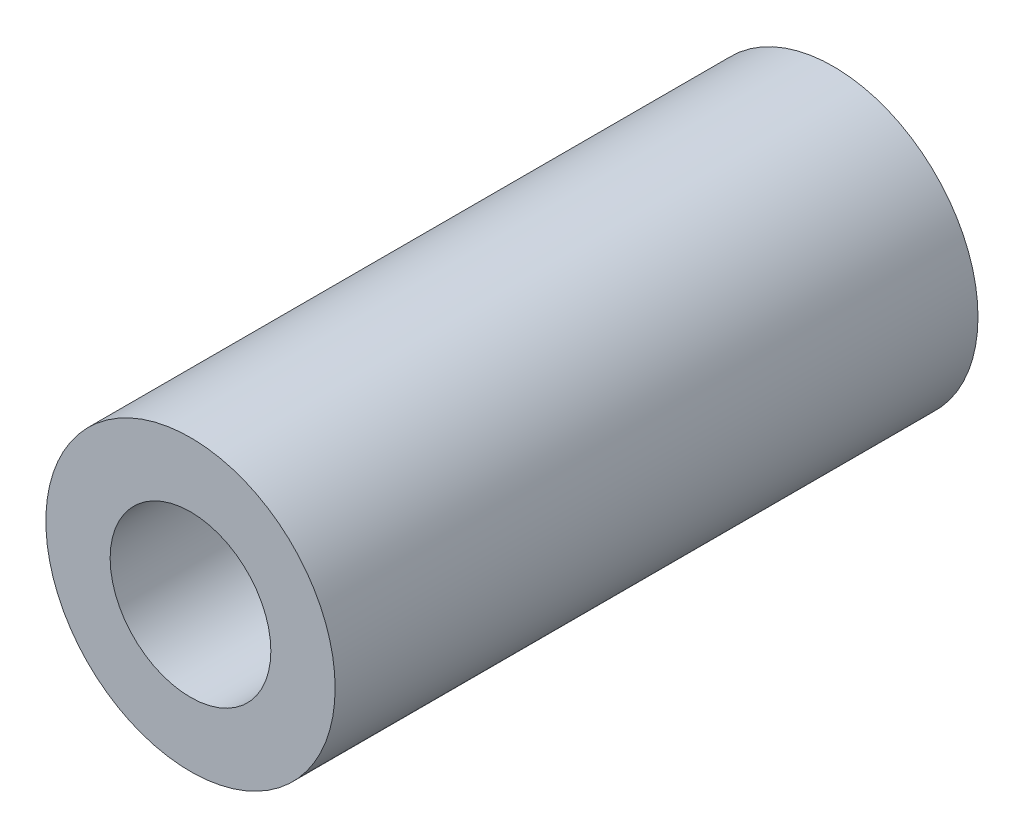
from build123d import *

# Parameters (mm, degrees)
SZKIC1_R                    = 3.15
SZKIC1_R_2                  = 1.75
DODANIE_WYCI_GNI_CIE1_DEPTH = 14


with BuildPart() as part:
    # Szkic1 → Dodanie-wyciągnięcie1 (new body)
    with BuildSketch(Plane.XY):
        Circle(SZKIC1_R)
        Circle(SZKIC1_R_2, mode=Mode.SUBTRACT)
    extrude(amount=DODANIE_WYCI_GNI_CIE1_DEPTH)


solid = part.part
